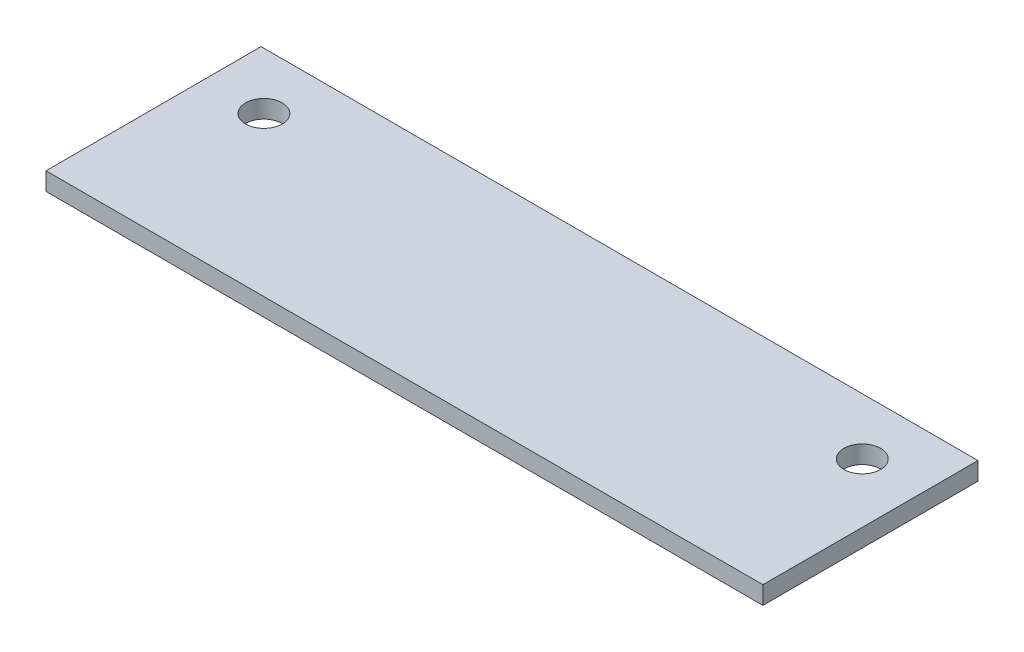
from build123d import *

# Parameters (mm, degrees)
SKETCH1_W           = 127
SKETCH1_H           = 76.2
BOSS_EXTRUDE1_DEPTH = 3.175
SKETCH3_W           = 127
SKETCH3_H           = 38.1
SKETCH3_R           = 3.25
CUT_EXTRUDE1_DEPTH  = 4.175


with BuildPart() as part:
    # Sketch1 → Boss-Extrude1 (new body)
    with BuildSketch(Plane(origin=(0, 0, 0), x_dir=(1, 0, 0), z_dir=(0, 1, 0))):
        Rectangle(SKETCH1_W, SKETCH1_H)
    extrude(amount=BOSS_EXTRUDE1_DEPTH)

    # Sketch3 → Cut-Extrude1 (cut, through all)
    with BuildSketch(Plane(origin=(0, 3.175, 0), x_dir=(1, 0, 0), z_dir=(0, 1, 0))):
        with Locations((0, -19.05)):
            Rectangle(SKETCH3_W, SKETCH3_H)
        with Locations((-53, 28.1)):
            Circle(SKETCH3_R)
        with Locations((53, 28.1)):
            Circle(SKETCH3_R)
    extrude(amount=-CUT_EXTRUDE1_DEPTH, mode=Mode.SUBTRACT)


solid = part.part
